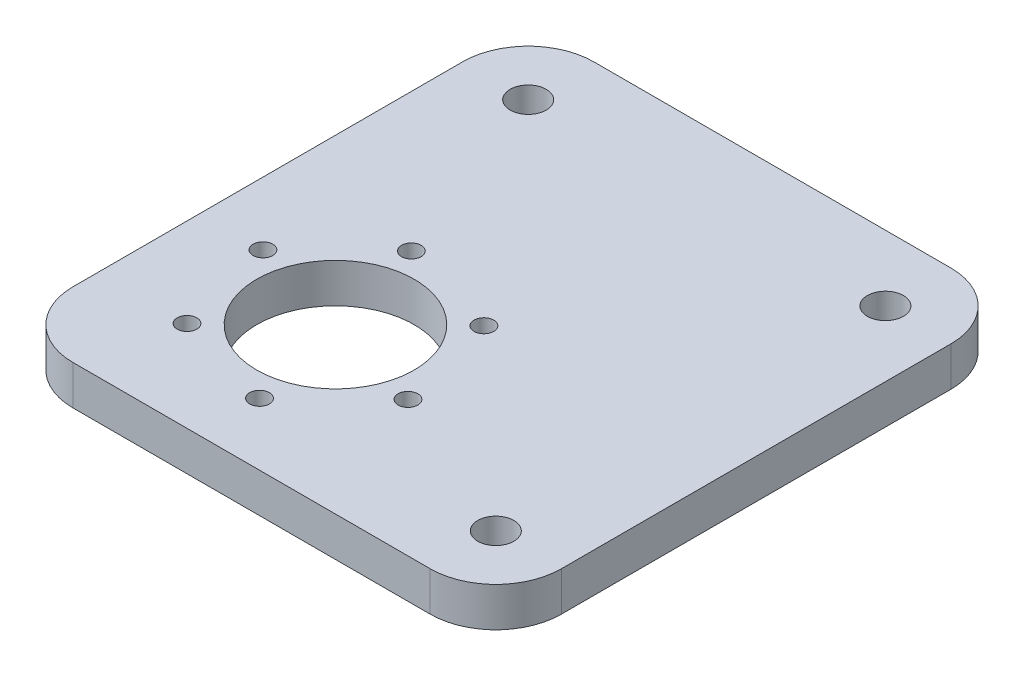
from build123d import *

# Parameters (mm, degrees)
SKETCH2_W           = 74.44
SKETCH2_H           = 79.38
SKETCH2_R           = 12
BOSS_EXTRUDE1_DEPTH = 6
SKETCH6_R           = 2.75
CUT_EXTRUDE2_DEPTH  = 10
SKETCH8_R           = 1.5
CUT_EXTRUDE4_DEPTH  = 7
FILLET1_R           = 10


with BuildPart() as part:
    # Sketch2 → Boss-Extrude1 (new body)
    with BuildSketch(Plane(origin=(0, 0, 0), x_dir=(1, 0, 0), z_dir=(0, 1, 0))):
        with Locations((18.526729133, 13.835644594)):
            Rectangle(SKETCH2_W, SKETCH2_H)
        with Locations((6.306729133, -0.854355406)):
            Circle(SKETCH2_R, mode=Mode.SUBTRACT)
    extrude(amount=BOSS_EXTRUDE1_DEPTH)

    # Sketch6 → Cut-Extrude2 (cut)
    with BuildSketch(Plane.XZ):
        with Locations((45.746729133, 15.854355406)):
            Circle(SKETCH6_R)
        with Locations((45.746729133, -43.525644594)):
            Circle(SKETCH6_R)
        with Locations((-8.693270867, -43.525644594)):
            Circle(SKETCH6_R)
    extrude(amount=-CUT_EXTRUDE2_DEPTH, mode=Mode.SUBTRACT)

    # Sketch8 → Cut-Extrude4 (cut, through all)
    with BuildSketch(Plane.XZ):
        with Locations((21.705664704, 5.198637084)):
            Circle(SKETCH8_R)
        with Locations((17.768455213, -10.30937315)):
            Circle(SKETCH8_R)
        with Locations((2.369519643, -14.653654828)):
            Circle(SKETCH8_R)
        with Locations((-9.092206437, -3.489926272)):
            Circle(SKETCH8_R)
        with Locations((-5.154996946, 12.018083962)):
            Circle(SKETCH8_R)
        with Locations((10.243938624, 16.36236564)):
            Circle(SKETCH8_R)
    extrude(amount=-CUT_EXTRUDE4_DEPTH, mode=Mode.SUBTRACT)

    # Fillet1
    fillet1_edges = [part.edges().sort_by_distance(p)[0] for p in [
        (-18.693270867, 3, -53.525644594),
        (55.746729133, 3, -53.525644594),
        (55.746729133, 3, 25.854355406),
        (-18.693270867, 3, 25.854355406),
    ]]
    fillet(fillet1_edges, radius=FILLET1_R)


solid = part.part
